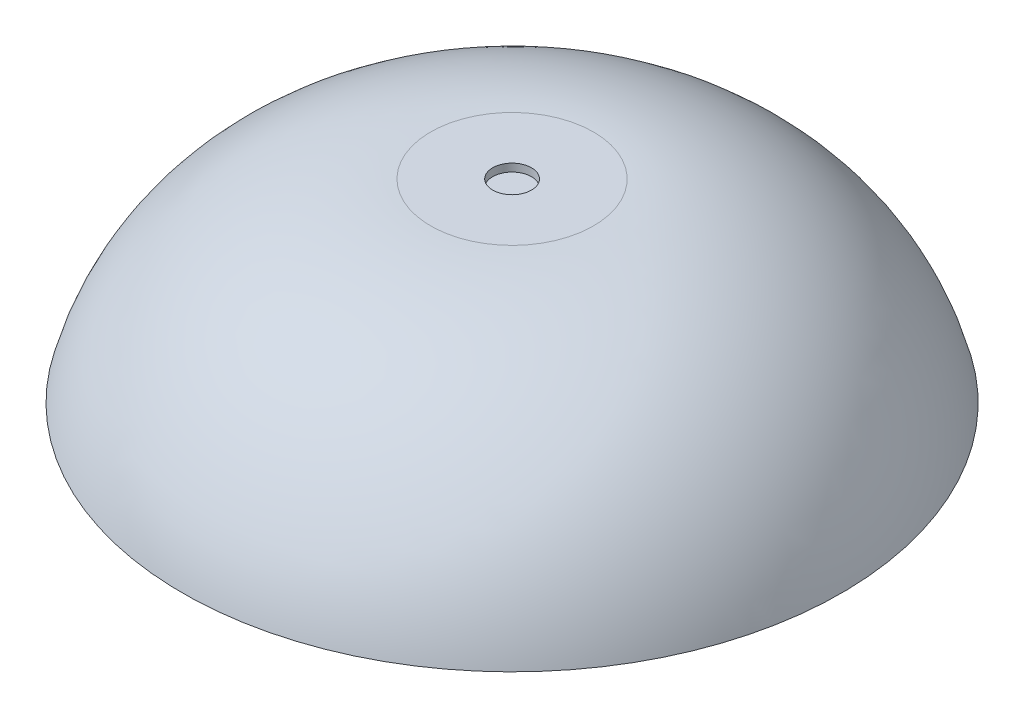
from build123d import *


with BuildPart() as part:
    # Croquis1 → Revolución1 (revolve)
    with BuildSketch(Plane.XY):
        with BuildLine():
            Line((0, 0), (85, 0))
            ThreePointArc((85, 0), (61.607881008, 36.018087691), (21, 50))
            Line((21, 50), (5, 50))
            Line((5, 50), (5, 48))
            Line((5, 48), (21, 48))
            ThreePointArc((21, 48), (59.354660734, 35.223997499), (82.386643498, 2))
            Line((82.386643498, 2), (0, 2))
            Line((0, 2), (0, 0))
        make_face()
    revolve(axis=Axis((0, 0, 0), (0, 1, 0)))


solid = part.part
